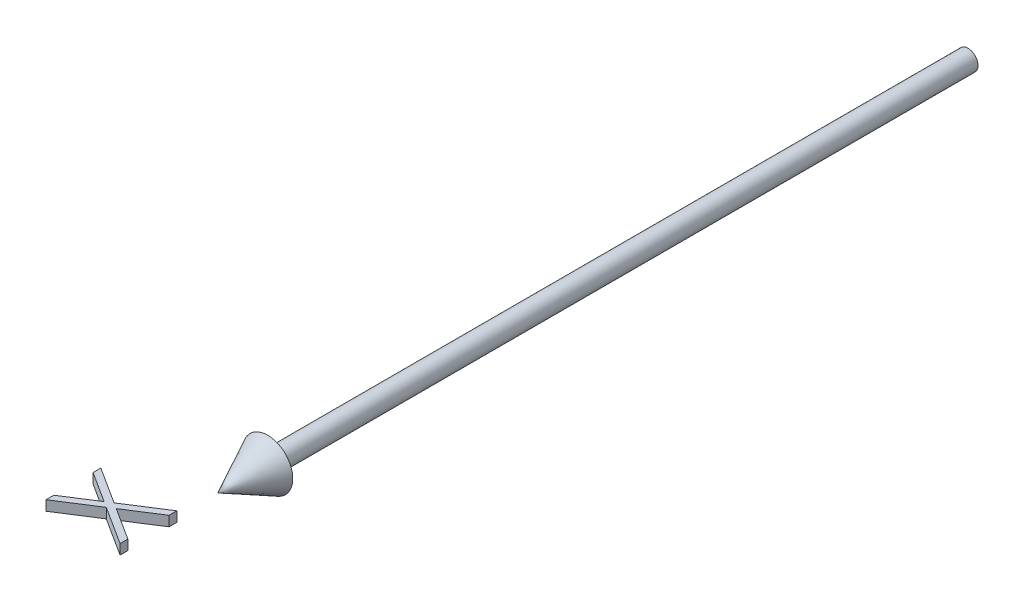
from build123d import *

# Parameters (mm, degrees)
BOSS_EXTRUDE1_DEPTH      = 1
BOSS_EXTRUDE1_DEPTH_BACK = 1


with BuildPart() as part:
    # Sketch2 → Revolve1 (revolve)
    with BuildSketch(Plane(origin=(0, 0, 0), x_dir=(1, 0, 0), z_dir=(0, 1, 0))):
        Polygon((0, -150), (5, -140), (2, -140), (2, 0), (0, 0), align=None)
    revolve(axis=Axis((0, 0, -41.949952025), (0, 0, 1)))


with BuildPart() as body_2:
    # Sketch3 → Boss-Extrude1 (new, two sides: drawn at the far end of the back side and taken through both)
    with BuildSketch(Plane(origin=(0, 0, 0), x_dir=(1, 0, 0), z_dir=(0, 1, 0)).offset(-BOSS_EXTRUDE1_DEPTH_BACK)):
        Polygon((-15, -158.365384615), (-15, -159.918870192), (-8.864182692, -163.846153846), (-15, -167.7734375), (-15, -169.326923077), (-7.650240385, -164.624399038), (0, -169.519230769), (0, -167.965745192), (-6.436298077, -163.846153846), (0, -159.7265625), (0, -158.173076923), (-7.650240385, -163.070913462), align=None)
    extrude(amount=BOSS_EXTRUDE1_DEPTH + BOSS_EXTRUDE1_DEPTH_BACK)


solid = Compound([part.part, body_2.part])
